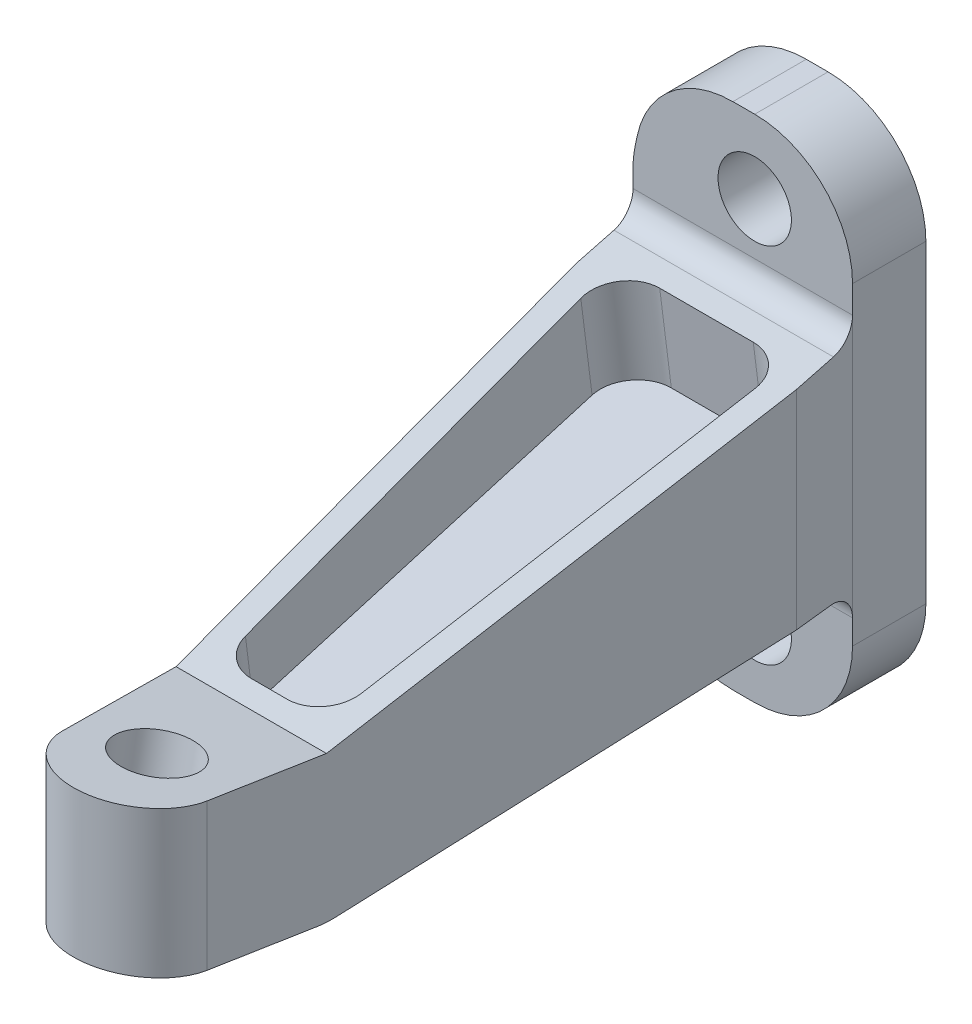
from build123d import *

# Parameters (mm, degrees)
SKETCH1_R           = 4.762499999999989
SKETCH1_R_2         = 4.762500000000005
BOSS_EXTRUDE1_DEPTH = 9.525
CHAMFER1_SIZE       = 88.89999999999999
CHAMFER1_SIZE2      = 6.20588556630559
CHAMFER2_SIZE       = 88.89999999999999
CHAMFER2_SIZE2      = 6.300746042301969
FILLET1_R           = 8.528649
CUT_EXTRUDE2_DEPTH  = 117.6635246642072
FILLET4_R           = 3.175
CUT_EXTRUDE3_REACH  = 119.909
FILLET5_R           = 12.7
FILLET6_R           = 12.7
SKETCH15_R          = 4.7624999999999975
CUT_EXTRUDE7_DEPTH  = 117.82072113018388
FILLET9_R           = 12.7
CUT_EXTRUDE8_REACH  = 121.538
FILLET10_R          = 12.7


with BuildPart() as part:
    # Sketch1 → Boss-Extrude1 (new body)
    # profile 1 of 3: a face of its own
    with BuildSketch(Plane.XY):
        Polygon((-28.50000000000001, 23.36447913627793), (-28.500000000000007, 17.01447913627793), (-1.421e-14, 17.01447913627793), (-1.388e-14, 36.06447913627791), (-25.877441230163292, 36.06447913627793), align=None)
        with Locations(Location((-12.700000000000017, 26.539479136277926, 0), (0, 0, 180))):
            Circle(SKETCH1_R, mode=Mode.SUBTRACT)
    # profile 2 of 3: a face of its own
    with BuildSketch(Plane.XY):
        Polygon((1.421e-14, -11.046434023496033), (-28.499999999999996, -11.046434023496033), (-28.499999999999996, -17.396434023496035), (-25.877441230163278, -30.09643402349603), (1.421e-14, -30.09643402349603), align=None)
        with Locations(Location((-12.699999999999989, -20.571434023496032, 0), (0, 0, 180))):
            Circle(SKETCH1_R_2, mode=Mode.SUBTRACT)
    # profile 3 of 3: a face of its own
    with BuildSketch(Plane.XY):
        Polygon((-28.500000000000007, 17.01447913627793), (-28.5, -11.046434023496033), (1.421e-14, -11.046434023496033), (-5.89e-15, 17.014479136277927), align=None)
    extrude(amount=BOSS_EXTRUDE1_DEPTH)

    # Sweep1: sweep along a path in Sketch4
    with BuildLine(Plane(origin=(0, -11.046434023496033, 0), x_dir=(1, 0, 0), z_dir=(0, 1, 0))) as sweep1_path:
        Line((-14.249999999999991, -9.525), (-5.144041152540681, -93.4757286489478))
        Line((-5.144041152540681, -93.4757286489478), (-3.7745316583277084, -106.10167193035296))
    # Sketch3 → Sweep1 (sweep)
    with BuildSketch(Plane.XY.offset(9.525)):
        Polygon((-28.499999999999996, -11.046434023496033), (1.388e-14, -11.046434023496033), (-1.388e-14, 17.01447913627793), (-28.50000000000001, 17.01447913627793), align=None)
    sweep(path=sweep1_path.line)

    # Chamfer1
    chamfer1_edges = [part.edges().sort_by_distance(p)[0] for p in [
        (10.475468341672286, 2.9840225563909506, 106.10167193035296),
    ]]
    chamfer1_side = [part.faces().sort_by_distance(p)[0] for p in [
        (5.237734170836156, 2.9840225563909497, 57.813335965176485),
    ]]
    chamfer(chamfer1_edges, length=CHAMFER1_SIZE, length2=CHAMFER1_SIZE2, reference=chamfer1_side[0])

    # Chamfer2
    chamfer2_edges = [part.edges().sort_by_distance(p)[0] for p in [
        (-18.02453165832772, 2.984022556390949, 106.10167193035296),
    ]]
    chamfer2_side = [part.faces().sort_by_distance(p)[0] for p in [
        (-23.26226582916385, 2.9840225563909497, 57.813335965176506),
    ]]
    chamfer(chamfer2_edges, length=CHAMFER2_SIZE, length2=CHAMFER2_SIZE2, reference=chamfer2_side[0])

    # Fillet1
    fillet1_edges = [part.edges().sort_by_distance(p)[0] for p in [
        (4.269582775366721, 2.984022556390949, 106.10167193035296),
        (-11.72378561602573, 2.984022556390949, 106.10167193035296),
    ]]
    fillet(fillet1_edges, radius=FILLET1_R)

    # Sketch6 → Cut-Extrude2 (cut, through all)
    with BuildSketch(Plane.ZY.offset(28.500000000000004)):
        Polygon((81.13920097504592, 8.003565976503973), (106.10167193035296, 12.697715932081872), (106.10167193035296, -6.352284067918128), (81.13920097504591, -11.046434023496026), (117.96042684070639, -22.85606140259037), (128.32769329374543, 30.37810454166645), (17.720068960516624, 36.90132837728653), (9.525, 17.01447913627794), align=None)
    extrude(amount=-CUT_EXTRUDE2_DEPTH, mode=Mode.SUBTRACT)

    # Fillet4
    fillet4_edges = [part.edges().sort_by_distance(p)[0] for p in [
        (-14.249999999999995, -11.046434023496033, 9.525),
        (-14.25000000000001, 17.01447913627793, 9.525),
    ]]
    fillet(fillet4_edges, radius=FILLET4_R)

    # Cut-Extrude3: up to this plane
    cut_extrude3_end = Plane(origin=(-1.02e-15, 5.153508696821327, 0.3242221424168255), z_dir=(0, -0.9980268393792456, -0.06278875598921893))
    # Sketch8 → Cut-Extrude3 (cut, up to the surface)
    with BuildSketch(Plane(origin=(-6.1e-15, 17.929113719354145, 2.255944834364728), x_dir=(1, 3.4e-16, 4e-17), z_dir=(0, 0.9921767086467868, 0.12484141467810073)), mode=Mode.PRIVATE) as cut_extrude3_sk1:
        with BuildLine():
            ThreePointArc((-6.960254723021977, -13.301909437066078), (-3.6571329134227537, -14.633550570696002), (-2.2011808134518622, -17.88379445084032))
            Line((-2.2011808134518622, -17.88379445084032), (-0.1706376662483526, -71.38713388044914))
            ThreePointArc((-0.1706376662483526, -71.38713388044914), (-1.4988527094483572, -74.87087067627415), (-4.929711575818469, -76.33024886667496))
            Line((-4.929711575818469, -76.33024886667496), (-9.56390547472291, -76.33024886667496))
            ThreePointArc((-9.56390547472291, -76.33024886667496), (-12.621598981127008, -75.21903859372955), (-14.252419863558515, -72.40395403030512))
            Line((-14.252419863558515, -72.40395403030512), (-23.79483884579154, -18.9006146006963))
            ThreePointArc((-23.79483884579154, -18.9006146006963), (-22.75761418401056, -15.006715930662008), (-19.10632445695593, -13.301909437066078))
            Line((-19.10632445695593, -13.301909437066078), (-6.960254723021977, -13.301909437066078))
        make_face()
    cut_extrude3_tool1 = split(extrude(cut_extrude3_sk1.sketch, amount=-CUT_EXTRUDE3_REACH, mode=Mode.PRIVATE), bisect_by=cut_extrude3_end, keep=Keep.BOTH, mode=Mode.PRIVATE)
    add(cut_extrude3_tool1.solids().sort_by_distance((-10.437775, 12.651733, 44.197908))[0], mode=Mode.SUBTRACT)

    # Fillet5
    fillet5_edges = [part.edges().sort_by_distance(p)[0] for p in [
        (-28.50000000000001, 23.36447913627793, 4.7625),
    ]]
    fillet(fillet5_edges, radius=FILLET5_R)

    # Fillet6
    fillet6_edges = [part.edges().sort_by_distance(p)[0] for p in [
        (-1.404e-14, 36.06447913627791, 4.7625),
        (-25.877441230163292, 36.06447913627793, 4.7625),
    ]]
    fillet(fillet6_edges, radius=FILLET6_R)

    # Sketch15 → Cut-Extrude7 (cut, through all)
    with BuildSketch(Plane(origin=(2.39e-15, -7.006748203781874, 1.317607012078891), x_dir=(1, 3.3e-16, -6e-17), z_dir=(0, 0.9827744470593327, -0.18480905336920886))):
        with Locations(Location((-5.144041152540709, -95.00998731918351, 0), (0, 0, 270))):
            Circle(SKETCH15_R)
    extrude(amount=-CUT_EXTRUDE7_DEPTH, mode=Mode.SUBTRACT)

    # Fillet9
    fillet9_edges = [part.edges().sort_by_distance(p)[0] for p in [
        (1.404e-14, -30.09643402349603, 4.7625),
        (-25.877441230163278, -30.09643402349603, 4.7625),
        (-28.499999999999996, -17.396434023496035, 4.7625),
    ]]
    fillet(fillet9_edges, radius=FILLET9_R)

    # Cut-Extrude8: up to this plane
    cut_extrude8_end = Plane(origin=(-3.9e-16, 1.9847734817922233, 0.12486784215105542), z_dir=(0, -0.9980268393792456, -0.06278875598921893))
    # Sketch16 → Cut-Extrude8 (cut, up to the surface)
    with BuildSketch(Plane.XZ.offset(11.046434023496033), mode=Mode.PRIVATE) as cut_extrude8_sk1:
        with BuildLine():
            Line((-19.021943533629052, 15.875), (-6.942808285990063, 15.874999999999996))
            ThreePointArc((-6.942808285990063, 15.874999999999996), (-3.6401991085921965, 17.206147661436145), (-2.183788559280739, 20.455462941157986))
            Line((-2.183788559280739, 20.455462941157986), (-0.17315756899978269, 73.01966391620381))
            ThreePointArc((-0.17315756899978269, 73.01966391620381), (-1.5008249571452126, 76.50431015244372), (-4.932177295709103, 77.9642009750459))
            Line((-4.932177295709103, 77.9642009750459), (-9.573100570431755, 77.9642009750459))
            ThreePointArc((-9.573100570431755, 77.9642009750459), (-12.628305718550124, 76.85507308214247), (-14.260471182334522, 74.04429399464112))
            Line((-14.260471182334522, 74.04429399464112), (-23.709314145531817, 21.480093019595273))
            ThreePointArc((-23.709314145531817, 21.480093019595273), (-22.67531564072565, 17.582294851881656), (-19.021943533629052, 15.875))
        make_face()
    cut_extrude8_tool1 = split(extrude(cut_extrude8_sk1.sketch, amount=-CUT_EXTRUDE8_REACH, mode=Mode.PRIVATE), bisect_by=cut_extrude8_end, keep=Keep.BOTH, mode=Mode.PRIVATE)
    add(cut_extrude8_tool1.solids().sort_by_distance((-10.411854, -11.046434, 44.429711))[0], mode=Mode.SUBTRACT)

    # Fillet10
    fillet10_edges = [part.edges().sort_by_distance(p)[0] for p in [
        (-6.448124287799661, -11.046434023496028, 81.13920097504591),
    ]]
    fillet(fillet10_edges, radius=FILLET10_R)


solid = part.part
